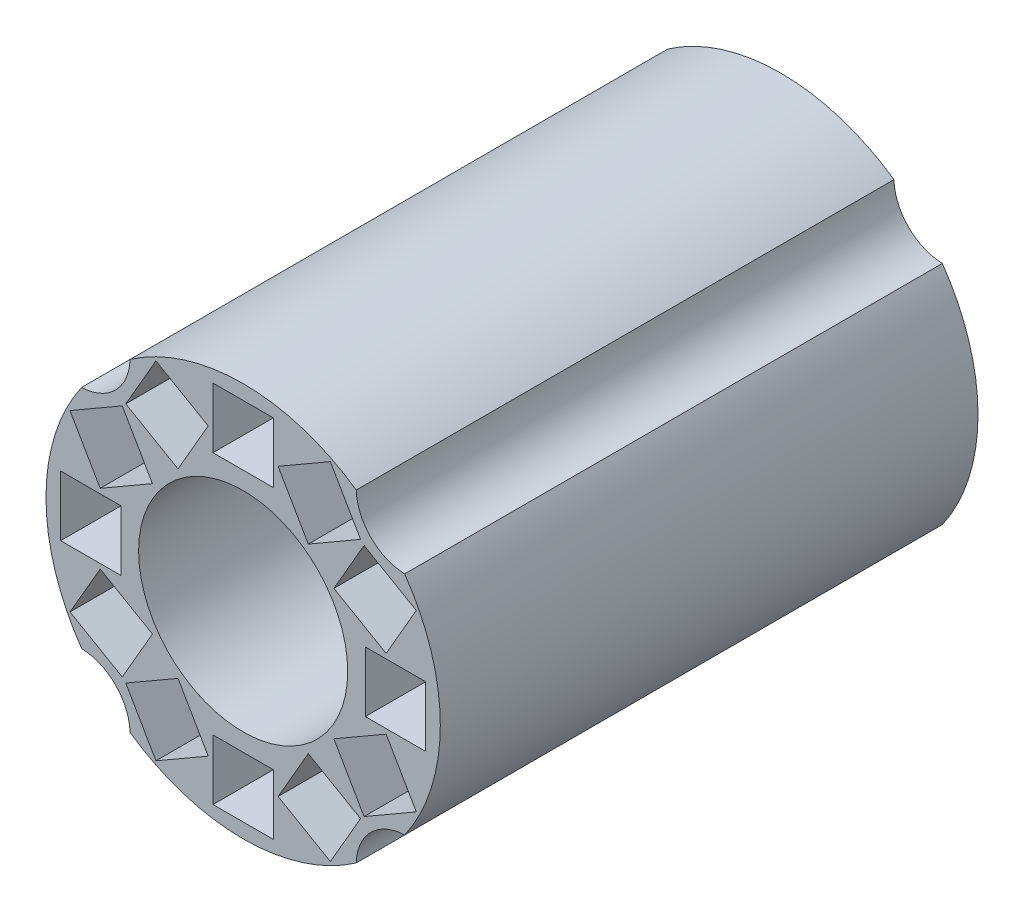
from build123d import *

# Parameters (mm, degrees)
SKETCH1_R            = 33
SKETCH1_R_2          = 17.5
SKETCH1_W            = 10.1
SKETCH1_H            = 10.1
BOSS_EXTRUDE1_DEPTH  = 90
CUT_EXTRUDE1_START   = -91
CUT_EXTRUDE1_DEPTH   = 92
MIRROR2_START        = -91
MIRROR2_COPY_1_DEPTH = 92


with BuildPart() as part:
    # Sketch1 → Boss-Extrude1 (new body)
    with BuildSketch(Plane.XY):
        Circle(SKETCH1_R)
        Circle(SKETCH1_R_2, mode=Mode.SUBTRACT)
        Polygon((15.185219507, 10.901571711), (20.235219507, 19.648428289), (28.982076086, 14.598428289), (23.932076086, 5.851571711), align=None, mode=Mode.SUBTRACT)
        with Locations((25.5, 0)):
            Rectangle(SKETCH1_W, SKETCH1_H, mode=Mode.SUBTRACT)
        Polygon((5.851571711, 23.932076086), (14.598428289, 28.982076086), (19.648428289, 20.235219507), (10.901571711, 15.185219507), align=None, mode=Mode.SUBTRACT)
        with Locations((0, 25.5)):
            Rectangle(SKETCH1_W, SKETCH1_H, mode=Mode.SUBTRACT)
        with Locations((-25.5, 0)):
            Rectangle(SKETCH1_W, SKETCH1_H, mode=Mode.SUBTRACT)
        Polygon((-23.932076086, 5.851571711), (-28.982076086, 14.598428289), (-20.235219507, 19.648428289), (-15.185219507, 10.901571711), align=None, mode=Mode.SUBTRACT)
        Polygon((-10.901571711, 15.185219507), (-19.648428289, 20.235219507), (-14.598428289, 28.982076086), (-5.851571711, 23.932076086), align=None, mode=Mode.SUBTRACT)
        Polygon((23.932076086, -5.851571711), (28.982076086, -14.598428289), (20.235219507, -19.648428289), (15.185219507, -10.901571711), align=None, mode=Mode.SUBTRACT)
        Polygon((10.901571711, -15.185219507), (19.648428289, -20.235219507), (14.598428289, -28.982076086), (5.851571711, -23.932076086), align=None, mode=Mode.SUBTRACT)
        with Locations((0, -25.5)):
            Rectangle(SKETCH1_W, SKETCH1_H, mode=Mode.SUBTRACT)
        Polygon((-5.851571711, -23.932076086), (-10.901571711, -15.185219507), (-19.648428289, -20.235219507), (-14.598428289, -28.982076086), align=None, mode=Mode.SUBTRACT)
        Polygon((-15.185219507, -10.901571711), (-23.932076086, -5.851571711), (-28.982076086, -14.598428289), (-20.235219507, -19.648428289), align=None, mode=Mode.SUBTRACT)
    extrude(amount=BOSS_EXTRUDE1_DEPTH)

    # Sketch2 → Cut-Extrude1 (cut)
    with BuildSketch(Plane.XY.offset(90).offset(CUT_EXTRUDE1_START)):
        with BuildLine():
            Line((-195.710732602, 14.035729655), (-27.032017462, 18.9280224))
            ThreePointArc((-27.032017462, 18.9280224), (-21.370045373, 21.370045373), (-18.9280224, 27.032017462))
            Line((-18.9280224, 27.032017462), (-14.035729655, 195.710732602))
            Line((-14.035729655, 195.710732602), (-252.683769537, 434.358772484))
            Line((-252.683769537, 434.358772484), (-434.358772484, 252.683769537))
            Line((-434.358772484, 252.683769537), (-195.710732602, 14.035729655))
        make_face()
    cut_extrude1 = extrude(amount=CUT_EXTRUDE1_DEPTH, mode=Mode.SUBTRACT)

    # Mirror1: Cut-Extrude1 across plane
    add(cut_extrude1.mirror(Plane(origin=(0, 0, 0), x_dir=(0, 0, 1), z_dir=(1, 0, 0))), mode=Mode.SUBTRACT)

    # Mirror2: Cut-Extrude1 across plane
    add(cut_extrude1.mirror(Plane.ZX), mode=Mode.SUBTRACT)

    # Mirror2 copy 1 sketch → Mirror2 copy 1 (cut)
    with BuildSketch(Plane(origin=(0, 0, 90), x_dir=(-1, 0, 0), z_dir=(0, 0, 1)).offset(MIRROR2_START)):
        with BuildLine():
            Line((-195.710732602, 14.035729655), (-27.032017462, 18.9280224))
            ThreePointArc((-27.032017462, 18.9280224), (-21.370045373, 21.370045373), (-18.9280224, 27.032017462))
            Line((-18.9280224, 27.032017462), (-14.035729655, 195.710732602))
            Line((-14.035729655, 195.710732602), (-252.683769537, 434.358772484))
            Line((-252.683769537, 434.358772484), (-434.358772484, 252.683769537))
            Line((-434.358772484, 252.683769537), (-195.710732602, 14.035729655))
        make_face()
    extrude(amount=MIRROR2_COPY_1_DEPTH, mode=Mode.SUBTRACT)


solid = part.part
